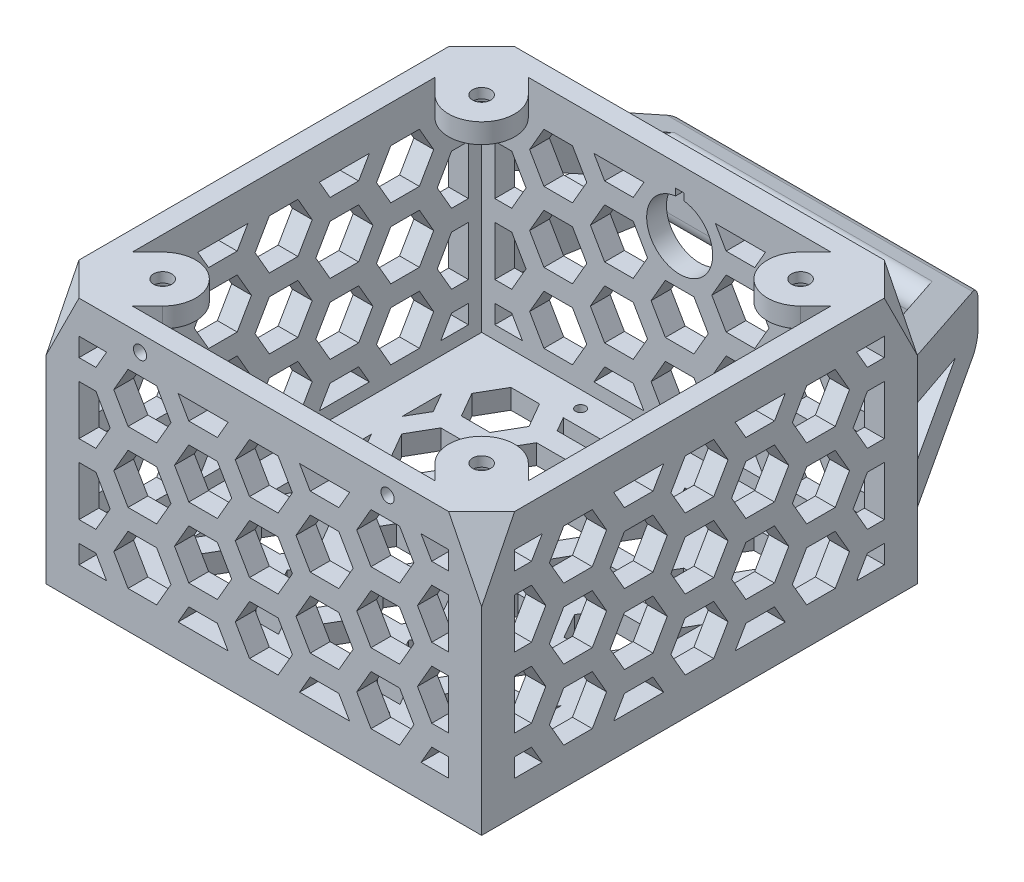
from build123d import *

# Parameters (mm, degrees)
SKETCH1_W                      = 120
SKETCH1_H                      = 120
BOSS_EXTRUDE2_DEPTH            = 6
SKETCH2_W                      = 132
SKETCH2_H                      = 80
BOSS_EXTRUDE3_DEPTH            = 6
SKETCH3_W                      = 120
SKETCH3_H                      = 80
BOSS_EXTRUDE4_DEPTH            = 6
BOSS_EXTRUDE5_START            = -40
BOSS_EXTRUDE5_DEPTH            = 20
CUT_EXTRUDE2_DEPTH             = 67
CUT_EXTRUDE2_DEPTH_BACK        = 67
FILLET2_R                      = 5
FILLET3_R                      = 5
FILLET4_R                      = 5
FILLET5_R                      = 5
CUT_EXTRUDE3_REACH             = 174
SKETCH9_R                      = 2
CUT_EXTRUDE3_DIRECTION_2_DEPTH = 1
SKETCH11_R                     = 2.75
BOSS_EXTRUDE8_DEPTH            = 6
SKETCH12_R                     = 6
CUT_EXTRUDE4_DEPTH             = 3
SKETCH13_R                     = 1.5
CUT_EXTRUDE5_DEPTH             = 7
CUT_EXTRUDE6_REACH             = 134
CUT_EXTRUDE7_START             = -94.338095117
CUT_EXTRUDE7_DEPTH             = 216.960461481
MIRROR4_START                  = -94.338095117
MIRROR4_COPY_1_DEPTH           = 216.960461481


with BuildPart() as part:
    # Sketch1 → Boss-Extrude2 (new body)
    with BuildSketch(Plane(origin=(0, 0, 0), x_dir=(1, 0, 0), z_dir=(0, 1, 0))):
        Rectangle(SKETCH1_W, SKETCH1_H)
        Polygon((8.660254038, 21.25), (4.330127019, 28.75), (-4.330127019, 28.75), (-8.660254038, 21.25), (-4.330127019, 13.75), (4.330127019, 13.75), align=None, mode=Mode.SUBTRACT)
        Polygon((8.660254038, 0), (4.330127019, 7.5), (-4.330127019, 7.5), (-8.660254038, 0), (-4.330127019, -7.5), (4.330127019, -7.5), align=None, mode=Mode.SUBTRACT)
        Polygon((8.660254038, 42.5), (4.330127019, 50), (-4.330127019, 50), (-8.660254038, 42.5), (-4.330127019, 35), (4.330127019, 35), align=None, mode=Mode.SUBTRACT)
        Polygon((8.660254038, -21.25), (4.330127019, -13.75), (-4.330127019, -13.75), (-8.660254038, -21.25), (-4.330127019, -28.75), (4.330127019, -28.75), align=None, mode=Mode.SUBTRACT)
        Polygon((8.660254038, -42.5), (4.330127019, -35), (-4.330127019, -35), (-8.660254038, -42.5), (-4.330127019, -50), (4.330127019, -50), align=None, mode=Mode.SUBTRACT)
        Polygon((27.063293868, 31.875), (22.733166849, 39.375), (14.072912811, 39.375), (9.742785793, 31.875), (14.072912811, 24.375), (22.733166849, 24.375), align=None, mode=Mode.SUBTRACT)
        Polygon((27.063293868, 10.625), (22.733166849, 18.125), (14.072912811, 18.125), (9.742785793, 10.625), (14.072912811, 3.125), (22.733166849, 3.125), align=None, mode=Mode.SUBTRACT)
        Polygon((11.547005384, 50), (14.072912811, 45.625), (22.733166849, 45.625), (25.259074277, 50), align=None, mode=Mode.SUBTRACT)
        Polygon((11.547005384, -50), (14.072912811, -45.625), (22.733166849, -45.625), (25.259074277, -50), align=None, mode=Mode.SUBTRACT)
        Polygon((22.733166849, -24.375), (27.063293868, -31.875), (22.733166849, -39.375), (14.072912811, -39.375), (9.742785793, -31.875), (14.072912811, -24.375), align=None, mode=Mode.SUBTRACT)
        Polygon((22.733166849, -3.125), (27.063293868, -10.625), (22.733166849, -18.125), (14.072912811, -18.125), (9.742785793, -10.625), (14.072912811, -3.125), align=None, mode=Mode.SUBTRACT)
        Polygon((45.466333699, 42.5), (41.13620668, 50), (32.475952642, 50), (28.145825623, 42.5), (32.475952642, 35), (41.13620668, 35), align=None, mode=Mode.SUBTRACT)
        Polygon((45.466333699, 21.25), (41.13620668, 28.75), (32.475952642, 28.75), (28.145825623, 21.25), (32.475952642, 13.75), (41.13620668, 13.75), align=None, mode=Mode.SUBTRACT)
        Polygon((45.466333699, 0), (41.13620668, 7.5), (32.475952642, 7.5), (28.145825623, 0), (32.475952642, -7.5), (41.13620668, -7.5), align=None, mode=Mode.SUBTRACT)
        Polygon((45.466333699, -21.25), (41.13620668, -13.75), (32.475952642, -13.75), (28.145825623, -21.25), (32.475952642, -28.75), (41.13620668, -28.75), align=None, mode=Mode.SUBTRACT)
        Polygon((45.466333699, -42.5), (41.13620668, -35), (32.475952642, -35), (28.145825623, -42.5), (32.475952642, -50), (41.13620668, -50), align=None, mode=Mode.SUBTRACT)
        Polygon((50, 37.852540378), (46.548865453, 31.875), (50, 25.897459622), align=None, mode=Mode.SUBTRACT)
        Polygon((50, 16.602540378), (46.548865453, 10.625), (50, 4.647459622), align=None, mode=Mode.SUBTRACT)
        Polygon((50, -16.602540378), (46.548865453, -10.625), (50, -4.647459622), align=None, mode=Mode.SUBTRACT)
        Polygon((50, -37.852540378), (46.548865453, -31.875), (50, -25.897459622), align=None, mode=Mode.SUBTRACT)
        Polygon((-46.548865453, -31.875), (-50, -25.897459622), (-50, -37.852540378), align=None, mode=Mode.SUBTRACT)
        Polygon((-46.548865453, -10.625), (-50, -4.647459622), (-50, -16.602540378), align=None, mode=Mode.SUBTRACT)
        Polygon((-50, 16.602540378), (-46.548865453, 10.625), (-50, 4.647459622), align=None, mode=Mode.SUBTRACT)
        Polygon((-50, 37.852540378), (-46.548865453, 31.875), (-50, 25.897459622), align=None, mode=Mode.SUBTRACT)
        Polygon((-41.13620668, 35), (-45.466333699, 42.5), (-41.13620668, 50), (-32.475952642, 50), (-28.145825623, 42.5), (-32.475952642, 35), align=None, mode=Mode.SUBTRACT)
        Polygon((-41.13620668, 13.75), (-45.466333699, 21.25), (-41.13620668, 28.75), (-32.475952642, 28.75), (-28.145825623, 21.25), (-32.475952642, 13.75), align=None, mode=Mode.SUBTRACT)
        Polygon((-41.13620668, -7.5), (-45.466333699, 0), (-41.13620668, 7.5), (-32.475952642, 7.5), (-28.145825623, 0), (-32.475952642, -7.5), align=None, mode=Mode.SUBTRACT)
        Polygon((-41.13620668, -28.75), (-45.466333699, -21.25), (-41.13620668, -13.75), (-32.475952642, -13.75), (-28.145825623, -21.25), (-32.475952642, -28.75), align=None, mode=Mode.SUBTRACT)
        Polygon((-41.13620668, -50), (-45.466333699, -42.5), (-41.13620668, -35), (-32.475952642, -35), (-28.145825623, -42.5), (-32.475952642, -50), align=None, mode=Mode.SUBTRACT)
        Polygon((-11.547005384, -50), (-25.259074277, -50), (-22.733166849, -45.625), (-14.072912811, -45.625), align=None, mode=Mode.SUBTRACT)
        Polygon((-14.072912811, -24.375), (-22.733166849, -24.375), (-27.063293868, -31.875), (-22.733166849, -39.375), (-14.072912811, -39.375), (-9.742785793, -31.875), align=None, mode=Mode.SUBTRACT)
        Polygon((-14.072912811, -3.125), (-22.733166849, -3.125), (-27.063293868, -10.625), (-22.733166849, -18.125), (-14.072912811, -18.125), (-9.742785793, -10.625), align=None, mode=Mode.SUBTRACT)
        Polygon((-22.733166849, 3.125), (-27.063293868, 10.625), (-22.733166849, 18.125), (-14.072912811, 18.125), (-9.742785793, 10.625), (-14.072912811, 3.125), align=None, mode=Mode.SUBTRACT)
        Polygon((-11.547005384, 50), (-14.072912811, 45.625), (-22.733166849, 45.625), (-25.259074277, 50), align=None, mode=Mode.SUBTRACT)
        Polygon((-22.733166849, 24.375), (-27.063293868, 31.875), (-22.733166849, 39.375), (-14.072912811, 39.375), (-9.742785793, 31.875), (-14.072912811, 24.375), align=None, mode=Mode.SUBTRACT)
    extrude(amount=BOSS_EXTRUDE2_DEPTH)

    # Sketch2 → Boss-Extrude3 (add)
    with BuildSketch(Plane.XY.offset(60)):
        with Locations((0, 40)):
            Rectangle(SKETCH2_W, SKETCH2_H)
        Polygon((8.660254038, 61.25), (4.330127019, 68.75), (-4.330127019, 68.75), (-8.660254038, 61.25), (-4.330127019, 53.75), (4.330127019, 53.75), align=None, mode=Mode.SUBTRACT)
        Polygon((8.660254038, 40), (4.330127019, 47.5), (-4.330127019, 47.5), (-8.660254038, 40), (-4.330127019, 32.5), (4.330127019, 32.5), align=None, mode=Mode.SUBTRACT)
        Polygon((4.330127019, 26.25), (8.660254038, 18.75), (4.330127019, 11.25), (-4.330127019, 11.25), (-8.660254038, 18.75), (-4.330127019, 26.25), align=None, mode=Mode.SUBTRACT)
        Polygon((27.063293868, 50.625), (22.733166849, 58.125), (14.072912811, 58.125), (9.742785793, 50.625), (14.072912811, 43.125), (22.733166849, 43.125), align=None, mode=Mode.SUBTRACT)
        Polygon((10.825317547, 70), (14.072912811, 64.375), (22.733166849, 64.375), (25.980762114, 70), align=None, mode=Mode.SUBTRACT)
        Polygon((22.733166849, 36.875), (27.063293868, 29.375), (22.733166849, 21.875), (14.072912811, 21.875), (9.742785793, 29.375), (14.072912811, 36.875), align=None, mode=Mode.SUBTRACT)
        Polygon((10.825317547, 10), (14.072912811, 15.625), (22.733166849, 15.625), (25.980762114, 10), align=None, mode=Mode.SUBTRACT)
        Polygon((45.466333699, 61.25), (41.13620668, 68.75), (32.475952642, 68.75), (28.145825623, 61.25), (32.475952642, 53.75), (41.13620668, 53.75), align=None, mode=Mode.SUBTRACT)
        Polygon((45.466333699, 40), (41.13620668, 47.5), (32.475952642, 47.5), (28.145825623, 40), (32.475952642, 32.5), (41.13620668, 32.5), align=None, mode=Mode.SUBTRACT)
        Polygon((41.13620668, 26.25), (45.466333699, 18.75), (41.13620668, 11.25), (32.475952642, 11.25), (28.145825623, 18.75), (32.475952642, 26.25), align=None, mode=Mode.SUBTRACT)
        Polygon((47.631397208, 70), (56, 70), (56, 64.375), (50.878992472, 64.375), align=None, mode=Mode.SUBTRACT)
        Polygon((56, 58.125), (50.878992472, 58.125), (46.548865453, 50.625), (50.878992472, 43.125), (56, 43.125), align=None, mode=Mode.SUBTRACT)
        Polygon((56, 21.875), (50.878992472, 21.875), (46.548865453, 29.375), (50.878992472, 36.875), (56, 36.875), align=None, mode=Mode.SUBTRACT)
        Polygon((47.631397208, 10), (50.878992472, 15.625), (56, 15.625), (56, 10), align=None, mode=Mode.SUBTRACT)
        Polygon((-50.878992472, 15.625), (-56, 15.625), (-56, 10), (-47.631397208, 10), align=None, mode=Mode.SUBTRACT)
        Polygon((-50.878992472, 36.875), (-56, 36.875), (-56, 21.875), (-50.878992472, 21.875), (-46.548865453, 29.375), align=None, mode=Mode.SUBTRACT)
        Polygon((-56, 58.125), (-50.878992472, 58.125), (-46.548865453, 50.625), (-50.878992472, 43.125), (-56, 43.125), align=None, mode=Mode.SUBTRACT)
        Polygon((-47.631397208, 70), (-56, 70), (-56, 64.375), (-50.878992472, 64.375), align=None, mode=Mode.SUBTRACT)
        Polygon((-41.13620668, 53.75), (-45.466333699, 61.25), (-41.13620668, 68.75), (-32.475952642, 68.75), (-28.145825623, 61.25), (-32.475952642, 53.75), align=None, mode=Mode.SUBTRACT)
        Polygon((-41.13620668, 32.5), (-45.466333699, 40), (-41.13620668, 47.5), (-32.475952642, 47.5), (-28.145825623, 40), (-32.475952642, 32.5), align=None, mode=Mode.SUBTRACT)
        Polygon((-32.475952642, 26.25), (-41.13620668, 26.25), (-45.466333699, 18.75), (-41.13620668, 11.25), (-32.475952642, 11.25), (-28.145825623, 18.75), align=None, mode=Mode.SUBTRACT)
        Polygon((-10.825317547, 10), (-25.980762114, 10), (-22.733166849, 15.625), (-14.072912811, 15.625), align=None, mode=Mode.SUBTRACT)
        Polygon((-14.072912811, 36.875), (-22.733166849, 36.875), (-27.063293868, 29.375), (-22.733166849, 21.875), (-14.072912811, 21.875), (-9.742785793, 29.375), align=None, mode=Mode.SUBTRACT)
        Polygon((-22.733166849, 43.125), (-27.063293868, 50.625), (-22.733166849, 58.125), (-14.072912811, 58.125), (-9.742785793, 50.625), (-14.072912811, 43.125), align=None, mode=Mode.SUBTRACT)
        Polygon((-10.825317547, 70), (-14.072912811, 64.375), (-22.733166849, 64.375), (-25.980762114, 70), align=None, mode=Mode.SUBTRACT)
    boss_extrude3 = extrude(amount=BOSS_EXTRUDE3_DEPTH)

    # Mirror1: Boss-Extrude3 across plane
    add(boss_extrude3.mirror(Plane.XY))

    # Sketch3 → Boss-Extrude4 (add)
    with BuildSketch(Plane.ZY.offset(60)):
        with Locations((0, 40)):
            Rectangle(SKETCH3_W, SKETCH3_H)
        Polygon((8.660254038, 40), (4.330127019, 47.5), (-4.330127019, 47.5), (-8.660254038, 40), (-4.330127019, 32.5), (4.330127019, 32.5), align=None, mode=Mode.SUBTRACT)
        Polygon((8.660254038, 61.25), (4.330127019, 68.75), (-4.330127019, 68.75), (-8.660254038, 61.25), (-4.330127019, 53.75), (4.330127019, 53.75), align=None, mode=Mode.SUBTRACT)
        Polygon((4.330127019, 26.25), (8.660254038, 18.75), (4.330127019, 11.25), (-4.330127019, 11.25), (-8.660254038, 18.75), (-4.330127019, 26.25), align=None, mode=Mode.SUBTRACT)
        Polygon((27.063293868, 50.625), (22.733166849, 58.125), (14.072912811, 58.125), (9.742785793, 50.625), (14.072912811, 43.125), (22.733166849, 43.125), align=None, mode=Mode.SUBTRACT)
        Polygon((10.825317547, 70), (14.072912811, 64.375), (22.733166849, 64.375), (25.980762114, 70), align=None, mode=Mode.SUBTRACT)
        Polygon((22.733166849, 36.875), (27.063293868, 29.375), (22.733166849, 21.875), (14.072912811, 21.875), (9.742785793, 29.375), (14.072912811, 36.875), align=None, mode=Mode.SUBTRACT)
        Polygon((10.825317547, 10), (14.072912811, 15.625), (22.733166849, 15.625), (25.980762114, 10), align=None, mode=Mode.SUBTRACT)
        Polygon((45.466333699, 61.25), (41.13620668, 68.75), (32.475952642, 68.75), (28.145825623, 61.25), (32.475952642, 53.75), (41.13620668, 53.75), align=None, mode=Mode.SUBTRACT)
        Polygon((45.466333699, 40), (41.13620668, 47.5), (32.475952642, 47.5), (28.145825623, 40), (32.475952642, 32.5), (41.13620668, 32.5), align=None, mode=Mode.SUBTRACT)
        Polygon((41.13620668, 26.25), (45.466333699, 18.75), (41.13620668, 11.25), (32.475952642, 11.25), (28.145825623, 18.75), (32.475952642, 26.25), align=None, mode=Mode.SUBTRACT)
        Polygon((47.631397208, 70), (56, 70), (56, 64.375), (50.878992472, 64.375), align=None, mode=Mode.SUBTRACT)
        Polygon((56, 58.125), (50.878992472, 58.125), (46.548865453, 50.625), (50.878992472, 43.125), (56, 43.125), align=None, mode=Mode.SUBTRACT)
        Polygon((56, 21.875), (50.878992472, 21.875), (46.548865453, 29.375), (50.878992472, 36.875), (56, 36.875), align=None, mode=Mode.SUBTRACT)
        Polygon((47.631397208, 10), (50.878992472, 15.625), (56, 15.625), (56, 10), align=None, mode=Mode.SUBTRACT)
        Polygon((-50.878992472, 15.625), (-56, 15.625), (-56, 10), (-47.631397208, 10), align=None, mode=Mode.SUBTRACT)
        Polygon((-50.878992472, 36.875), (-56, 36.875), (-56, 21.875), (-50.878992472, 21.875), (-46.548865453, 29.375), align=None, mode=Mode.SUBTRACT)
        Polygon((-56, 58.125), (-50.878992472, 58.125), (-46.548865453, 50.625), (-50.878992472, 43.125), (-56, 43.125), align=None, mode=Mode.SUBTRACT)
        Polygon((-47.631397208, 70), (-56, 70), (-56, 64.375), (-50.878992472, 64.375), align=None, mode=Mode.SUBTRACT)
        Polygon((-41.13620668, 53.75), (-45.466333699, 61.25), (-41.13620668, 68.75), (-32.475952642, 68.75), (-28.145825623, 61.25), (-32.475952642, 53.75), align=None, mode=Mode.SUBTRACT)
        Polygon((-41.13620668, 32.5), (-45.466333699, 40), (-41.13620668, 47.5), (-32.475952642, 47.5), (-28.145825623, 40), (-32.475952642, 32.5), align=None, mode=Mode.SUBTRACT)
        Polygon((-32.475952642, 26.25), (-41.13620668, 26.25), (-45.466333699, 18.75), (-41.13620668, 11.25), (-32.475952642, 11.25), (-28.145825623, 18.75), align=None, mode=Mode.SUBTRACT)
        Polygon((-10.825317547, 10), (-25.980762114, 10), (-22.733166849, 15.625), (-14.072912811, 15.625), align=None, mode=Mode.SUBTRACT)
        Polygon((-14.072912811, 36.875), (-22.733166849, 36.875), (-27.063293868, 29.375), (-22.733166849, 21.875), (-14.072912811, 21.875), (-9.742785793, 29.375), align=None, mode=Mode.SUBTRACT)
        Polygon((-22.733166849, 43.125), (-27.063293868, 50.625), (-22.733166849, 58.125), (-14.072912811, 58.125), (-9.742785793, 50.625), (-14.072912811, 43.125), align=None, mode=Mode.SUBTRACT)
        Polygon((-10.825317547, 70), (-14.072912811, 64.375), (-22.733166849, 64.375), (-25.980762114, 70), align=None, mode=Mode.SUBTRACT)
    boss_extrude4 = extrude(amount=BOSS_EXTRUDE4_DEPTH)

    # Mirror2: Boss-Extrude4 across plane
    add(boss_extrude4.mirror(Plane(origin=(0, 0, 0), x_dir=(0, 0, 1), z_dir=(1, 0, 0))))

    # Sketch4 → Boss-Extrude5 (add, symmetric)
    with BuildSketch(Plane.XZ.offset(BOSS_EXTRUDE5_START)):
        Polygon((-66, -66), (-44.4, -106), (44.4, -106), (66, -66), (56, -66), (42.5, -91), (-42.5, -91), (-56, -66), align=None)
    extrude(amount=BOSS_EXTRUDE5_DEPTH, both=True)

    # Sketch5 → Cut-Extrude2 (cut, two sides)
    with BuildSketch(Plane(origin=(0, 0, 0), x_dir=(0, 0, -1), z_dir=(1, 0, 0))) as cut_extrude2_sk:
        Polygon((106, 20), (66, 20), (106, 32.5), align=None)
        Polygon((66, 60), (106, 47.5), (106, 60), align=None)
        Polygon((66, 32.5), (91, 40), (66, 47.5), align=None)
    extrude(amount=CUT_EXTRUDE2_DEPTH, mode=Mode.SUBTRACT)
    extrude(cut_extrude2_sk.sketch, amount=-CUT_EXTRUDE2_DEPTH_BACK, mode=Mode.SUBTRACT)

    # Fillet2
    fillet2_edges = [part.edges().sort_by_distance(p)[0] for p in [
        (0, 47.5, -106),
    ]]
    fillet(fillet2_edges, radius=FILLET2_R)

    # Fillet3
    fillet3_edges = [part.edges().sort_by_distance(p)[0] for p in [
        (0, 32.5, -106),
    ]]
    fillet(fillet3_edges, radius=FILLET3_R)

    # Fillet4
    fillet4_edges = [part.edges().sort_by_distance(p)[0] for p in [
        (0, 52.1875, -91),
    ]]
    fillet(fillet4_edges, radius=FILLET4_R)

    # Fillet5
    fillet5_edges = [part.edges().sort_by_distance(p)[0] for p in [
        (0, 27.8125, -91),
    ]]
    fillet(fillet5_edges, radius=FILLET5_R)

    # Sketch9 → Cut-Extrude3 (cut, up to next)
    with BuildSketch(Plane.XY.offset(66), mode=Mode.PRIVATE) as cut_extrude3_sk1:
        with Locations((-37.5, 75)):
            Circle(SKETCH9_R)
    cut_extrude3_tool1 = extrude(cut_extrude3_sk1.sketch, amount=-CUT_EXTRUDE3_REACH, mode=Mode.PRIVATE) & part.part
    add(cut_extrude3_tool1.solids().sort_by_distance((-37.5, 75, 66))[0], mode=Mode.SUBTRACT)
    # Sketch9 → Cut-Extrude3 (cut, up to next)
    with BuildSketch(Plane.XY.offset(66), mode=Mode.PRIVATE) as cut_extrude3_sk2:
        with Locations((37.5, 75)):
            Circle(SKETCH9_R)
    cut_extrude3_tool2 = extrude(cut_extrude3_sk2.sketch, amount=-CUT_EXTRUDE3_REACH, mode=Mode.PRIVATE) & part.part
    add(cut_extrude3_tool2.solids().sort_by_distance((37.5, 75, 66))[0], mode=Mode.SUBTRACT)

    # Sketch9 → Cut-Extrude3 direction 2 (cut)
    with BuildSketch(Plane.XY.offset(66)):
        with Locations((-37.5, 75)):
            Circle(SKETCH9_R)
        with Locations((37.5, 75)):
            Circle(SKETCH9_R)
    extrude(amount=CUT_EXTRUDE3_DIRECTION_2_DEPTH, mode=Mode.SUBTRACT)

    # Sketch11 → Boss-Extrude8 (add)
    with BuildSketch(Plane(origin=(0, 80, 0), x_dir=(1, 0, 0), z_dir=(0, 1, 0))):
        with BuildLine():
            Line((-55.393398282, 41.251262658), (-60, 45.857864376))
            Line((-60, 45.857864376), (-60, 60))
            Line((-60, 60), (-45.857864376, 60))
            Line((-45.857864376, 60), (-41.251262658, 55.393398282))
            ThreePointArc((-41.251262658, 55.393398282), (-41.251262658, 41.251262658), (-55.393398282, 41.251262658))
        make_face()
        with Locations((-48.32233047, 48.32233047)):
            Circle(SKETCH11_R, mode=Mode.SUBTRACT)
        with BuildLine():
            Line((41.251262658, 55.393398282), (45.857864376, 60))
            Line((45.857864376, 60), (60, 60))
            Line((60, 60), (60, 45.857864376))
            Line((60, 45.857864376), (55.393398282, 41.251262658))
            ThreePointArc((55.393398282, 41.251262658), (41.251262658, 41.251262658), (41.251262658, 55.393398282))
        make_face()
        with Locations((48.32233047, 48.32233047)):
            Circle(SKETCH11_R, mode=Mode.SUBTRACT)
        with BuildLine():
            Line((55.393398282, -41.251262658), (60, -45.857864376))
            Line((60, -45.857864376), (60, -60))
            Line((60, -60), (45.857864376, -60))
            Line((45.857864376, -60), (41.251262658, -55.393398282))
            ThreePointArc((41.251262658, -55.393398282), (41.251262658, -41.251262658), (55.393398282, -41.251262658))
        make_face()
        with Locations((48.32233047, -48.32233047)):
            Circle(SKETCH11_R, mode=Mode.SUBTRACT)
        with BuildLine():
            Line((-41.251262658, -55.393398282), (-45.857864376, -60))
            Line((-45.857864376, -60), (-60, -60))
            Line((-60, -60), (-60, -45.857864376))
            Line((-60, -45.857864376), (-55.393398282, -41.251262658))
            ThreePointArc((-55.393398282, -41.251262658), (-41.251262658, -41.251262658), (-41.251262658, -55.393398282))
        make_face()
        with Locations((-48.32233047, -48.32233047)):
            Circle(SKETCH11_R, mode=Mode.SUBTRACT)
    extrude(amount=-BOSS_EXTRUDE8_DEPTH)

    # Sketch12 → Cut-Extrude4 (cut)
    with BuildSketch(Plane.XZ.offset(-74)):
        with Locations((-48.32233047, 48.32233047)):
            Circle(SKETCH12_R)
        with Locations((-48.32233047, -48.32233047)):
            Circle(SKETCH12_R)
        with Locations((48.32233047, -48.32233047)):
            Circle(SKETCH12_R)
        with Locations((48.32233047, 48.32233047)):
            Circle(SKETCH12_R)
    extrude(amount=-CUT_EXTRUDE4_DEPTH, mode=Mode.SUBTRACT)

    # Sketch13 → Cut-Extrude5 (cut, through all)
    with BuildSketch(Plane(origin=(0, 6, 0), x_dir=(1, 0, 0), z_dir=(0, 1, 0))):
        with Locations((-25, 55)):
            Circle(SKETCH13_R)
        with Locations((25, 55)):
            Circle(SKETCH13_R)
        with Locations((25, -55)):
            Circle(SKETCH13_R)
        with Locations((-25, -55)):
            Circle(SKETCH13_R)
    extrude(amount=-CUT_EXTRUDE5_DEPTH, mode=Mode.SUBTRACT)

    # Sketch14 → Cut-Extrude6 (cut, up to next)
    with BuildSketch(Plane(origin=(0, 0, -66), x_dir=(-1, 0, 0), z_dir=(0, 0, -1)), mode=Mode.PRIVATE) as cut_extrude6_sk1:
        with BuildLine():
            Line((0, 73.25), (-1.25, 73.25))
            Line((-1.25, 73.25), (-1.25, 71.171567416))
            ThreePointArc((-1.25, 71.171567416), (0, 51.25), (1.25, 71.171567416))
            Line((1.25, 71.171567416), (1.25, 73.25))
            Line((1.25, 73.25), (0, 73.25))
        make_face()
    cut_extrude6_tool1 = extrude(cut_extrude6_sk1.sketch, amount=-CUT_EXTRUDE6_REACH, mode=Mode.PRIVATE) & part.part
    add(cut_extrude6_tool1.solids().sort_by_distance((0, 61.424332, -66))[0], mode=Mode.SUBTRACT)

    # Sketch16 → Cut-Extrude7 (cut)
    with BuildSketch(Plane(origin=(0, 0, 0), x_dir=(-0.707106781, 0, 0.707106781), z_dir=(-0.707106781, 0, -0.707106781)).offset(CUT_EXTRUDE7_START)):
        Polygon((86.267027305, 80), (93.338095117, 80), (93.338095117, 60), align=None)
    cut_extrude7 = extrude(amount=CUT_EXTRUDE7_DEPTH, mode=Mode.SUBTRACT)

    # Mirror3: Cut-Extrude7 across plane
    add(cut_extrude7.mirror(Plane(origin=(0, 0, 0), x_dir=(0, 0, 1), z_dir=(1, 0, 0))), mode=Mode.SUBTRACT)

    # Mirror4: Cut-Extrude7 across plane
    add(cut_extrude7.mirror(Plane.XY), mode=Mode.SUBTRACT)

    # Mirror4 copy 1 sketch → Mirror4 copy 1 (cut)
    with BuildSketch(Plane(origin=(0, 0, 0), x_dir=(0.707106781, 0, -0.707106781), z_dir=(0.707106781, 0, 0.707106781)).offset(MIRROR4_START)):
        Polygon((86.267027305, 80), (93.338095117, 80), (93.338095117, 60), align=None)
    extrude(amount=MIRROR4_COPY_1_DEPTH, mode=Mode.SUBTRACT)


solid = part.part
